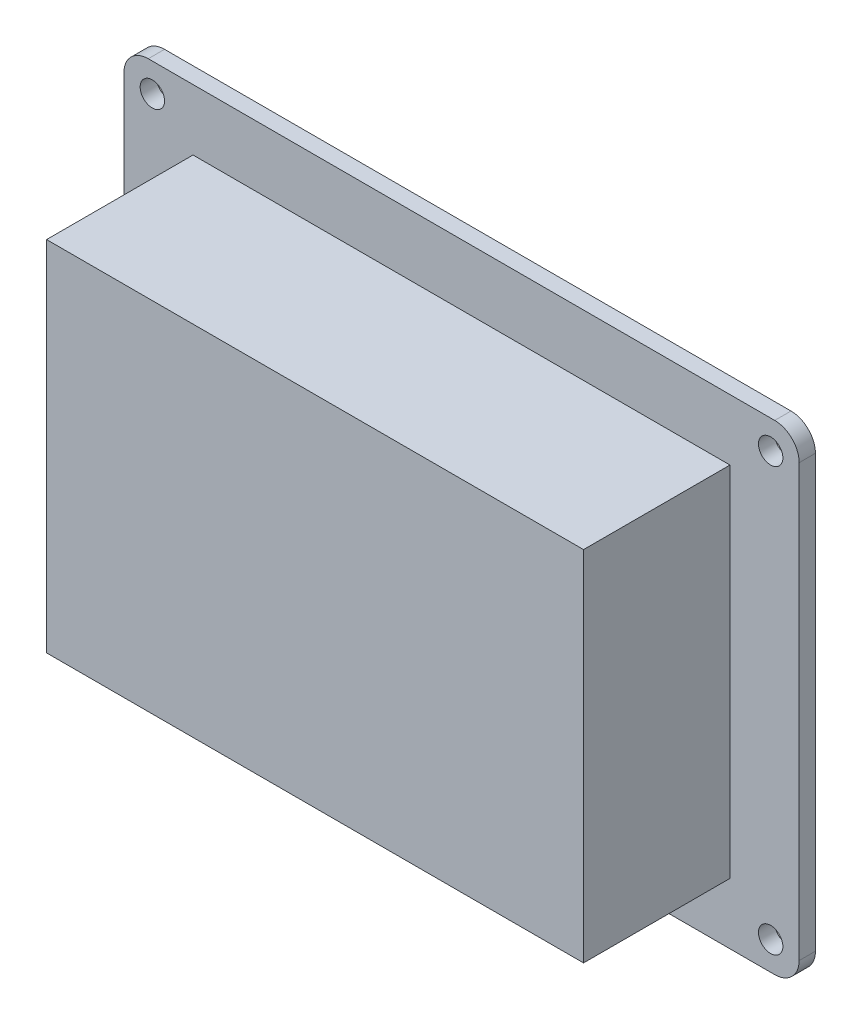
from build123d import *

# Parameters (mm, degrees)
SKETCH1_W           = 83
SKETCH1_H           = 59
BOSS_EXTRUDE1_DEPTH = 2
FILLET1_R           = 3
SKETCH2_R           = 1.5
CUT_EXTRUDE1_DEPTH  = 2
SKETCH4_W           = 66
SKETCH4_H           = 44
BOSS_EXTRUDE2_DEPTH = 18


with BuildPart() as part:
    # Sketch1 → Boss-Extrude1 (new body)
    with BuildSketch(Plane.XY):
        with Locations((41.5, 29.5)):
            Rectangle(SKETCH1_W, SKETCH1_H)
    extrude(amount=BOSS_EXTRUDE1_DEPTH)

    # Fillet1
    fillet1_edges = [part.edges().sort_by_distance(p)[0] for p in [
        (0, 59, 1),
        (83, 59, 1),
        (83, 0, 1),
        (0, 0, 1),
    ]]
    fillet(fillet1_edges, radius=FILLET1_R)

    # Sketch2 → Cut-Extrude1 (cut)
    with BuildSketch(Plane.XY.offset(2)):
        with Locations((3.5, 55.5)):
            Circle(SKETCH2_R)
        with Locations((79.5, 55.5)):
            Circle(SKETCH2_R)
    cut_extrude1 = extrude(amount=-CUT_EXTRUDE1_DEPTH, mode=Mode.SUBTRACT)

    # Mirror1: Cut-Extrude1 across plane
    add(cut_extrude1.mirror(Plane(origin=(0, 29.5, 0), x_dir=(0, 0, 1), z_dir=(0, -1, 0))), mode=Mode.SUBTRACT)

    # Sketch4 → Boss-Extrude2 (add)
    with BuildSketch(Plane.XY.offset(2)):
        with Locations((41.5, 29.5)):
            Rectangle(SKETCH4_W, SKETCH4_H)
    extrude(amount=BOSS_EXTRUDE2_DEPTH)


solid = part.part
